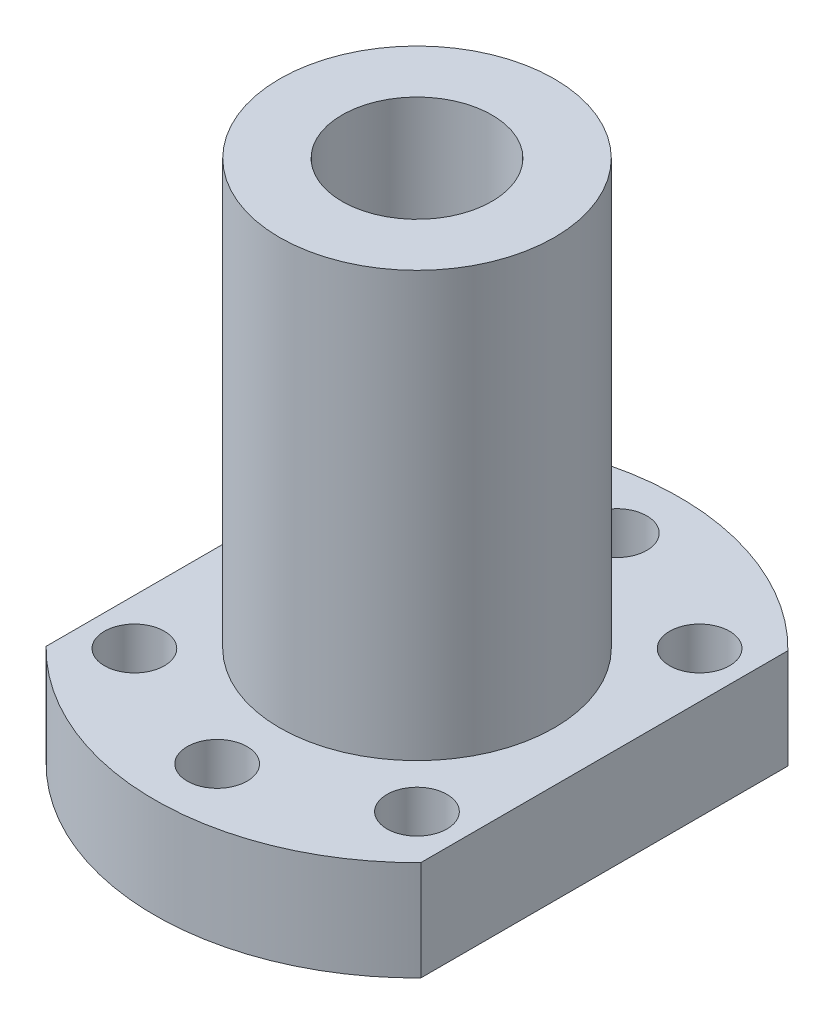
from build123d import *

# Parameters (mm, degrees)
SKETCH_1_R          = 2.4
SKETCH_1_R_2        = 11
EXTRUDE_1_DEPTH     = 8
SKETCH_1_3_R        = 11
SKETCH_1_3_R_2      = 6
EXTRUDE_2_DEPTH     = 42
SKETCH_2_R          = 3
CUT_EXTRUDE_1_DEPTH = 20


with BuildPart() as part:
    # 草图1 → 凸台-拉伸1 (new body)
    with BuildSketch(Plane(origin=(0, 0, 0), x_dir=(1, 0, 0), z_dir=(0, 1, 0))):
        with BuildLine():
            ThreePointArc((15, 14.696938457), (0, 21), (-15, 14.696938457))
            Line((-15, 14.696938457), (-15, -14.696938457))
            ThreePointArc((-15, -14.696938457), (0, -21), (15, -14.696938457))
            Line((15, -14.696938457), (15, 14.696938457))
        make_face()
        with Locations((-11.313708499, -11.313708499)):
            Circle(SKETCH_1_R, mode=Mode.SUBTRACT)
        with Locations((0, -16)):
            Circle(SKETCH_1_R, mode=Mode.SUBTRACT)
        with Locations((11.313708499, -11.313708499)):
            Circle(SKETCH_1_R, mode=Mode.SUBTRACT)
        with Locations((-11.313708499, 11.313708499)):
            Circle(SKETCH_1_R, mode=Mode.SUBTRACT)
        Circle(SKETCH_1_R_2, mode=Mode.SUBTRACT)
        with Locations((0, 16)):
            Circle(SKETCH_1_R, mode=Mode.SUBTRACT)
        with Locations((11.313708499, 11.313708499)):
            Circle(SKETCH_1_R, mode=Mode.SUBTRACT)
    extrude(amount=EXTRUDE_1_DEPTH)

    # 草图1<3> → 凸台-拉伸2 (add)
    with BuildSketch(Plane(origin=(0, 0, 0), x_dir=(1, 0, 0), z_dir=(0, 1, 0))):
        Circle(SKETCH_1_3_R)
        Circle(SKETCH_1_3_R_2, mode=Mode.SUBTRACT)
    extrude(amount=EXTRUDE_2_DEPTH)

    # 草图2 → 切除-拉伸1 (cut)
    with BuildSketch(Plane.ZY.offset(15)):
        with Locations((0, 4)):
            Circle(SKETCH_2_R)
    extrude(amount=-CUT_EXTRUDE_1_DEPTH, mode=Mode.SUBTRACT)


solid = part.part
